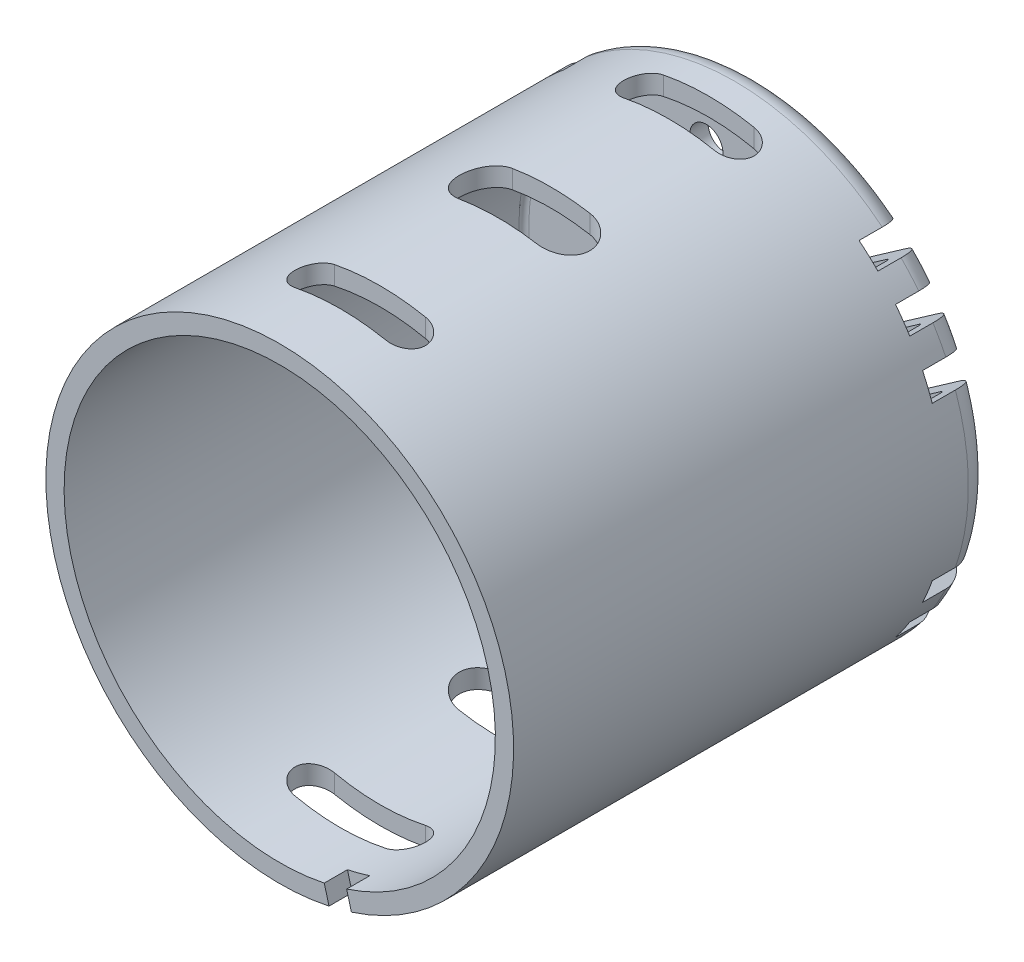
from build123d import *

# Parameters (mm, degrees)
SKETCH2_R                = 2.8448
CUT_EXTRUDE1_DEPTH       = 48.602256565
SHELL1_T                 = -1.397
SKETCH3_R                = 4.2418
CUT_EXTRUDE2_DEPTH       = 39.37
SKETCH5_R                = 4.7498
CUT_EXTRUDE7_DEPTH       = 25.4
CUT_EXTRUDE8_DEPTH       = 3.556
SKETCH7_R                = 1.27
CUT_EXTRUDE9_DEPTH       = 45.570457834
CUT_EXTRUDE10_DEPTH      = 48.602256565
CUT_EXTRUDE10_DEPTH_BACK = 48.602256565
CUT_EXTRUDE11_DEPTH      = 1.778


with BuildPart() as part:
    # Sketch1 → Revolve1 (revolve)
    with BuildSketch(Plane(origin=(0, 0, 0), x_dir=(0, 0, -1), z_dir=(1, 0, 0)), mode=Mode.PRIVATE) as revolve1_sk:
        with BuildLine():
            Line((0, 2.8448), (0, 4.6101))
            ThreePointArc((0, 4.6101), (-0.29757951, 5.32852049), (-1.016, 5.6261))
            Line((-1.016, 5.6261), (-3.5052, 5.6261))
            ThreePointArc((-3.5052, 5.6261), (-3.864410245, 5.774889755), (-4.0132, 6.1341))
            Line((-4.0132, 6.1341), (-4.0132, 6.5151))
            ThreePointArc((-4.0132, 6.5151), (-3.976002561, 6.604902561), (-3.8862, 6.6421))
            Line((-3.8862, 6.6421), (-3.8354, 6.6421))
            ThreePointArc((-3.8354, 6.6421), (-3.691715902, 6.701615902), (-3.6322, 6.8453))
            Line((-3.6322, 6.8453), (-3.6322, 16.1544))
            ThreePointArc((-3.6322, 16.1544), (-4.152964143, 17.411635857), (-5.4102, 17.9324))
            Line((-5.4102, 17.9324), (-40.2844, 17.9324))
            Line((-40.2844, 17.9324), (-40.2844, 0))
            Line((-40.2844, 0), (-3.438914748, 0))
            Line((-3.438914748, 0), (-3.438914748, 2.8448))
            Line((-3.438914748, 2.8448), (0, 2.8448))
        make_face()
    revolve(revolve1_sk.sketch.rotate(Axis((0, 0, 0), (0, 0, 1)), 90), axis=Axis((0, 0, 0), (0, 0, 1)))

    # Sketch2 → Cut-Extrude1 (cut, through all)
    with BuildSketch(Plane(origin=(0, 0, 0), x_dir=(-1, 0, 0), z_dir=(0, 0, -1))):
        Circle(SKETCH2_R)
    extrude(amount=-CUT_EXTRUDE1_DEPTH, mode=Mode.SUBTRACT)

    # Shell1
    shell1_openings = [part.faces().sort_by_distance(p)[0] for p in [
        (17.425195134, 0, 40.2844),
    ]]
    offset(amount=SHELL1_T, openings=shell1_openings, kind=Kind.INTERSECTION)

    # Sketch3 → Cut-Extrude2 (cut)
    with BuildSketch(Plane.XY.offset(40.2844)):
        Circle(SKETCH3_R)
    extrude(amount=-CUT_EXTRUDE2_DEPTH, mode=Mode.SUBTRACT)

    # Sketch5 → Cut-Extrude7 (cut)
    with BuildSketch(Plane.XY.offset(0.9144)):
        with Locations(Location((0, 0, 0), (0, 0, 180))):
            Circle(SKETCH5_R)
    extrude(amount=CUT_EXTRUDE7_DEPTH, mode=Mode.SUBTRACT)

    # Sketch6 → Cut-Extrude8 (cut)
    with BuildSketch(Plane(origin=(0, 0, 3.6322), x_dir=(-1, 0, 0), z_dir=(0, 0, -1))):
        with BuildLine():
            Line((-15.919300921, 12.309602304), (-7.921898448, 6.709760806))
            ThreePointArc((-7.921898448, 6.709760806), (-7.687987681, 5.383186928), (-9.014561559, 5.149276162))
            Line((-9.014561559, 5.149276162), (-17.011964033, 10.74911766))
            ThreePointArc((-17.011964033, 10.74911766), (-17.245874799, 12.075691537), (-15.919300921, 12.309602304))
        make_face()
        with BuildLine():
            Line((-15.919300921, -12.309602304), (-7.921898448, -6.709760806))
            ThreePointArc((-7.921898448, -6.709760806), (-7.687987681, -5.383186928), (-9.014561559, -5.149276162))
            Line((-9.014561559, -5.149276162), (-17.011964033, -10.74911766))
            ThreePointArc((-17.011964033, -10.74911766), (-17.245874799, -12.075691537), (-15.919300921, -12.309602304))
        make_face()
        with BuildLine():
            Line((15.919300921, 12.309602304), (7.921898448, 6.709760806))
            ThreePointArc((7.921898448, 6.709760806), (7.687987681, 5.383186928), (9.014561559, 5.149276162))
            Line((9.014561559, 5.149276162), (17.011964033, 10.74911766))
            ThreePointArc((17.011964033, 10.74911766), (17.245874799, 12.075691537), (15.919300921, 12.309602304))
        make_face()
        with BuildLine():
            Line((-13.767693375, 15.609220037), (-5.025586397, 9.487930831))
            ThreePointArc((-5.025586397, 9.487930831), (-4.791675631, 8.161356953), (-6.118249508, 7.927446187))
            Line((-6.118249508, 7.927446187), (-14.860356487, 14.048735393))
            ThreePointArc((-14.860356487, 14.048735393), (-15.094267253, 15.37530927), (-13.767693375, 15.609220037))
        make_face()
        with BuildLine():
            Line((-18.784549719, 9.509681555), (-9.541927257, 3.037927634))
            ThreePointArc((-9.541927257, 3.037927634), (-9.30801649, 1.711353756), (-10.634590368, 1.47744299))
            Line((-10.634590368, 1.47744299), (-19.87721283, 7.949196911))
            ThreePointArc((-19.87721283, 7.949196911), (-20.111123597, 9.275770788), (-18.784549719, 9.509681555))
        make_face()
        with BuildLine():
            Line((-18.784549719, -9.509681555), (-9.541927257, -3.037927634))
            ThreePointArc((-9.541927257, -3.037927634), (-9.30801649, -1.711353756), (-10.634590368, -1.47744299))
            Line((-10.634590368, -1.47744299), (-19.87721283, -7.949196911))
            ThreePointArc((-19.87721283, -7.949196911), (-20.111123597, -9.275770788), (-18.784549719, -9.509681555))
        make_face()
        with BuildLine():
            Line((-13.767693375, -15.609220037), (-5.025586397, -9.487930831))
            ThreePointArc((-5.025586397, -9.487930831), (-4.791675631, -8.161356953), (-6.118249508, -7.927446187))
            Line((-6.118249508, -7.927446187), (-14.860356487, -14.048735393))
            ThreePointArc((-14.860356487, -14.048735393), (-15.094267253, -15.37530927), (-13.767693375, -15.609220037))
        make_face()
        with BuildLine():
            Line((18.784549719, 9.509681555), (9.541927257, 3.037927634))
            ThreePointArc((9.541927257, 3.037927634), (9.30801649, 1.711353756), (10.634590368, 1.47744299))
            Line((10.634590368, 1.47744299), (19.87721283, 7.949196911))
            ThreePointArc((19.87721283, 7.949196911), (20.111123597, 9.275770788), (18.784549719, 9.509681555))
        make_face()
        with BuildLine():
            Line((13.767693375, 15.609220037), (5.025586397, 9.487930831))
            ThreePointArc((5.025586397, 9.487930831), (4.791675631, 8.161356953), (6.118249508, 7.927446187))
            Line((6.118249508, 7.927446187), (14.860356487, 14.048735393))
            ThreePointArc((14.860356487, 14.048735393), (15.094267253, 15.37530927), (13.767693375, 15.609220037))
        make_face()
        with BuildLine():
            Line((13.767693375, -15.609220037), (5.025586397, -9.487930831))
            ThreePointArc((5.025586397, -9.487930831), (4.791675631, -8.161356953), (6.118249508, -7.927446187))
            Line((6.118249508, -7.927446187), (14.860356487, -14.048735393))
            ThreePointArc((14.860356487, -14.048735393), (15.094267253, -15.37530927), (13.767693375, -15.609220037))
        make_face()
        with BuildLine():
            Line((15.919300921, -12.309602304), (7.921898448, -6.709760806))
            ThreePointArc((7.921898448, -6.709760806), (7.687987681, -5.383186928), (9.014561559, -5.149276162))
            Line((9.014561559, -5.149276162), (17.011964033, -10.74911766))
            ThreePointArc((17.011964033, -10.74911766), (17.245874799, -12.075691537), (15.919300921, -12.309602304))
        make_face()
        with BuildLine():
            Line((18.784549719, -9.509681555), (9.541927257, -3.037927634))
            ThreePointArc((9.541927257, -3.037927634), (9.30801649, -1.711353756), (10.634590368, -1.47744299))
            Line((10.634590368, -1.47744299), (19.87721283, -7.949196911))
            ThreePointArc((19.87721283, -7.949196911), (20.111123597, -9.275770788), (18.784549719, -9.509681555))
        make_face()
    extrude(amount=-CUT_EXTRUDE8_DEPTH, mode=Mode.SUBTRACT)

    # Sketch7 → Cut-Extrude9 (cut, through all)
    with BuildSketch(Plane(origin=(0, 0, 3.6322), x_dir=(-1, 0, 0), z_dir=(0, 0, -1))):
        with Locations((-2.54, 12.3317)):
            Circle(SKETCH7_R)
        with Locations((2.54, 12.3317)):
            Circle(SKETCH7_R)
        with Locations((2.54, -12.3317)):
            Circle(SKETCH7_R)
        with Locations((-2.54, -12.3317)):
            Circle(SKETCH7_R)
    extrude(amount=-CUT_EXTRUDE9_DEPTH, mode=Mode.SUBTRACT)

    # Sketch8 → Cut-Extrude10 (cut, two sides)
    with BuildSketch(Plane(origin=(0, 0, 0), x_dir=(1, 0, 0), z_dir=(0, 1, 0))) as cut_extrude10_sk:
        with BuildLine():
            Line((-3.4798, -32.5882), (3.4798, -32.5882))
            ThreePointArc((3.4798, -32.5882), (5.0038, -34.1122), (3.4798, -35.6362))
            Line((3.4798, -35.6362), (-3.4798, -35.6362))
            ThreePointArc((-3.4798, -35.6362), (-5.0038, -34.1122), (-3.4798, -32.5882))
        make_face()
        with BuildLine():
            Line((-3.4798, -10.4394), (3.4798, -10.4394))
            ThreePointArc((3.4798, -10.4394), (5.0038, -8.9154), (3.4798, -7.3914))
            Line((3.4798, -7.3914), (-3.4798, -7.3914))
            ThreePointArc((-3.4798, -7.3914), (-5.0038, -8.9154), (-3.4798, -10.4394))
        make_face()
        with BuildLine():
            Line((-2.9718, -19.4818), (2.9718, -19.4818))
            ThreePointArc((2.9718, -19.4818), (5.0038, -21.5138), (2.9718, -23.5458))
            Line((2.9718, -23.5458), (-2.9718, -23.5458))
            ThreePointArc((-2.9718, -23.5458), (-5.0038, -21.5138), (-2.9718, -19.4818))
        make_face()
    extrude(amount=CUT_EXTRUDE10_DEPTH, mode=Mode.SUBTRACT)
    extrude(cut_extrude10_sk.sketch, amount=-CUT_EXTRUDE10_DEPTH_BACK, mode=Mode.SUBTRACT)

    # Sketch10 → Cut-Extrude11 (cut)
    with BuildSketch(Plane.XY.offset(40.2844)):
        with BuildLine():
            Line((3.414778684, -16.178959784), (3.776831709, -17.530160068))
            ThreePointArc((3.776831709, -17.530160068), (4.641246644, -17.321368287), (5.494247828, -17.069979806))
            Line((5.494247828, -17.069979806), (5.132194803, -15.718779522))
            ThreePointArc((5.132194803, -15.718779522), (4.279676438, -15.971969908), (3.414778684, -16.178959784))
        make_face()
    extrude(amount=-CUT_EXTRUDE11_DEPTH, mode=Mode.SUBTRACT)


solid = part.part
